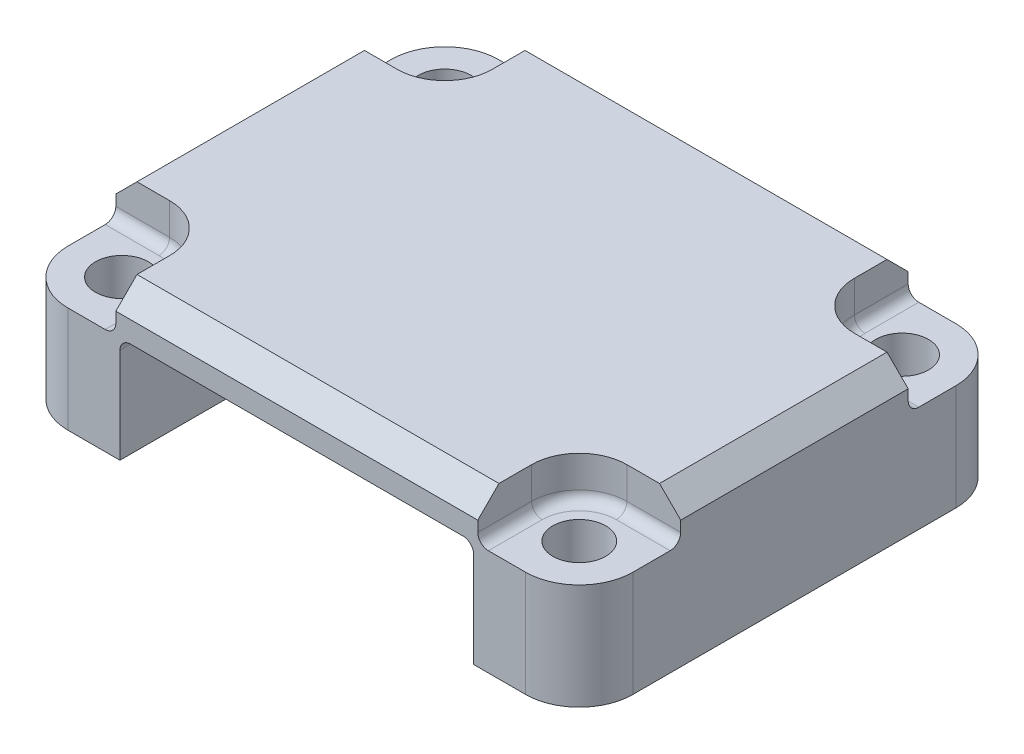
from build123d import *

# Parameters (mm, degrees)
SKETCH1_R           = 1.25
BOSS_EXTRUDE1_DEPTH = 7
SKETCH2_W           = 16.7
SKETCH2_H           = 20.32
CUT_EXTRUDE1_DEPTH  = 5
SKETCH3_R           = 1.25
CUT_EXTRUDE2_DEPTH  = 2
CHAMFER1_SIZE       = 1
FILLET1_R           = 0.5
FILLET2_R           = 0.5


with BuildPart() as part:
    # Sketch1 → Boss-Extrude1 (new body)
    with BuildSketch(Plane(origin=(0, -16.169464744, 0), x_dir=(1, 0, 0), z_dir=(0, 1, 0))):
        with BuildLine():
            Line((-127.05696299, -71.463712198), (-127.05696299, -86.703712198))
            ThreePointArc((-127.05696299, -86.703712198), (-127.800911766, -88.499763423), (-129.59696299, -89.243712198))
            Line((-129.59696299, -89.243712198), (-151.18696299, -89.243712198))
            ThreePointArc((-151.18696299, -89.243712198), (-152.983014214, -88.499763423), (-153.72696299, -86.703712198))
            Line((-153.72696299, -86.703712198), (-153.72696299, -71.463712198))
            ThreePointArc((-153.72696299, -71.463712198), (-152.983014214, -69.667660974), (-151.18696299, -68.923712198))
            Line((-151.18696299, -68.923712198), (-129.59696299, -68.923712198))
            ThreePointArc((-129.59696299, -68.923712198), (-127.800911766, -69.667660974), (-127.05696299, -71.463712198))
        make_face()
        with Locations((-151.18696299, -71.463712198)):
            Circle(SKETCH1_R, mode=Mode.SUBTRACT)
        with Locations((-151.18696299, -86.703712198)):
            Circle(SKETCH1_R, mode=Mode.SUBTRACT)
        with Locations((-129.59696299, -86.703712198)):
            Circle(SKETCH1_R, mode=Mode.SUBTRACT)
        with Locations((-129.59696299, -71.463712198)):
            Circle(SKETCH1_R, mode=Mode.SUBTRACT)
    extrude(amount=BOSS_EXTRUDE1_DEPTH)

    # Sketch2 → Cut-Extrude1 (cut)
    with BuildSketch(Plane.XZ.offset(16.169464744)):
        with Locations((-140.39196299, 79.083712198)):
            Rectangle(SKETCH2_W, SKETCH2_H)
    extrude(amount=-CUT_EXTRUDE1_DEPTH, mode=Mode.SUBTRACT)

    # Sketch3 → Cut-Extrude2 (cut)
    with BuildSketch(Plane(origin=(0, -9.169464744, 0), x_dir=(1, 0, 0), z_dir=(0, 1, 0))):
        with BuildLine():
            Line((-131.84696299, -86.703712198), (-131.84696299, -89.243712198))
            Line((-131.84696299, -89.243712198), (-129.59696299, -89.243712198))
            ThreePointArc((-129.59696299, -89.243712198), (-127.800911766, -88.499763423), (-127.05696299, -86.703712198))
            Line((-127.05696299, -86.703712198), (-127.05696299, -84.453712198))
            Line((-127.05696299, -84.453712198), (-129.59696299, -84.453712198))
            ThreePointArc((-129.59696299, -84.453712198), (-131.187953248, -85.112721941), (-131.84696299, -86.703712198))
        make_face()
        with Locations((-129.59696299, -86.703712198)):
            Circle(SKETCH3_R, mode=Mode.SUBTRACT)
        with BuildLine():
            Line((-151.18696299, -89.243712198), (-148.93696299, -89.243712198))
            Line((-148.93696299, -89.243712198), (-148.93696299, -86.703712198))
            ThreePointArc((-148.93696299, -86.703712198), (-149.595972732, -85.112721941), (-151.18696299, -84.453712198))
            Line((-151.18696299, -84.453712198), (-153.72696299, -84.453712198))
            Line((-153.72696299, -84.453712198), (-153.72696299, -86.703712198))
            ThreePointArc((-153.72696299, -86.703712198), (-152.983014214, -88.499763423), (-151.18696299, -89.243712198))
        make_face()
        with Locations((-151.18696299, -86.703712198)):
            Circle(SKETCH3_R, mode=Mode.SUBTRACT)
        with BuildLine():
            Line((-153.72696299, -71.463712198), (-153.72696299, -73.713712198))
            Line((-153.72696299, -73.713712198), (-151.18696299, -73.713712198))
            ThreePointArc((-151.18696299, -73.713712198), (-149.595972732, -73.054702456), (-148.93696299, -71.463712198))
            Line((-148.93696299, -71.463712198), (-148.93696299, -68.923712198))
            Line((-148.93696299, -68.923712198), (-151.18696299, -68.923712198))
            ThreePointArc((-151.18696299, -68.923712198), (-152.983014214, -69.667660974), (-153.72696299, -71.463712198))
        make_face()
        with Locations((-151.18696299, -71.463712198)):
            Circle(SKETCH3_R, mode=Mode.SUBTRACT)
        with BuildLine():
            Line((-129.59696299, -73.713712198), (-127.05696299, -73.713712198))
            Line((-127.05696299, -73.713712198), (-127.05696299, -71.463712198))
            ThreePointArc((-127.05696299, -71.463712198), (-127.800911766, -69.667660974), (-129.59696299, -68.923712198))
            Line((-129.59696299, -68.923712198), (-131.84696299, -68.923712198))
            Line((-131.84696299, -68.923712198), (-131.84696299, -71.463712198))
            ThreePointArc((-131.84696299, -71.463712198), (-131.187953248, -73.054702456), (-129.59696299, -73.713712198))
        make_face()
        with Locations((-129.59696299, -71.463712198)):
            Circle(SKETCH3_R, mode=Mode.SUBTRACT)
    extrude(amount=-CUT_EXTRUDE2_DEPTH, mode=Mode.SUBTRACT)

    # Chamfer1
    chamfer1_edges = [part.edges().sort_by_distance(p)[0] for p in [
        (-127.05696299, -9.169464744, 79.083712198),
        (-153.72696299, -9.169464744, 79.083712198),
        (-140.39196299, -9.169464744, 68.923712198),
        (-140.39196299, -9.169464744, 89.243712198),
    ]]
    chamfer(chamfer1_edges, length=CHAMFER1_SIZE)

    # Fillet1
    fillet1_edges = [part.edges().sort_by_distance(p)[0] for p in [
        (-148.74196299, -11.169464744, 79.083712198),
        (-132.04196299, -11.169464744, 79.083712198),
    ]]
    fillet(fillet1_edges, radius=FILLET1_R)

    # Fillet2
    fillet2_edges = [part.edges().sort_by_distance(p)[0] for p in [
        (-148.93696299, -11.169464744, 87.973712198),
        (-152.45696299, -11.169464744, 84.453712198),
        (-149.595972732, -11.169464744, 85.112721941),
        (-131.187953248, -11.169464744, 85.112721941),
        (-128.32696299, -11.169464744, 84.453712198),
        (-131.84696299, -11.169464744, 87.973712198),
        (-131.84696299, -11.169464744, 70.193712198),
        (-128.32696299, -11.169464744, 73.713712198),
        (-131.187953248, -11.169464744, 73.054702456),
        (-149.595972732, -11.169464744, 73.054702456),
        (-152.45696299, -11.169464744, 73.713712198),
        (-148.93696299, -11.169464744, 70.193712198),
    ]]
    fillet(fillet2_edges, radius=FILLET2_R)


solid = part.part
